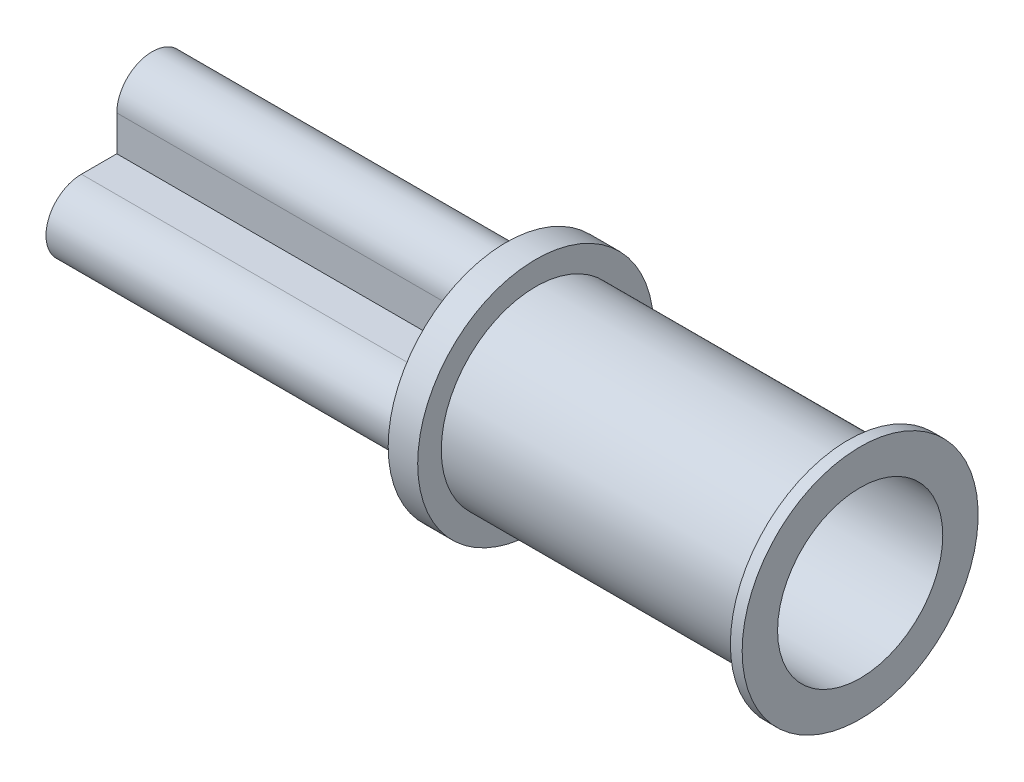
from build123d import *

# Parameters (mm, degrees)
BOSS_EXTRUDE1_DEPTH = 7.62


with BuildPart() as part:
    # Sketch1 → Revolve1 (revolve)
    with BuildSketch(Plane.XY):
        Polygon((0, 1.778), (0, 2.54), (0.635, 2.54), (0.635, 2.032), (7.366, 2.032), (7.366, 2.54), (7.62, 2.54), (7.62, 1.778), (0.635, 1.778), (0.635, 0), (0, 0), align=None)
    revolve(axis=Axis((0, 0, 0), (1, 0, 0)))

    # Sketch3 → Boss-Extrude1 (add)
    with BuildSketch(Plane(origin=(0, 0, 0), x_dir=(0, 0, -1), z_dir=(1, 0, 0))):
        with BuildLine():
            Line((-1.524, 0.762), (-0.762, 0.762))
            Line((-0.762, 0.762), (-0.762, 1.524))
            ThreePointArc((-0.762, 1.524), (0, 2.286), (0.762, 1.524))
            Line((0.762, 1.524), (0.762, 0.762))
            Line((0.762, 0.762), (1.524, 0.762))
            ThreePointArc((1.524, 0.762), (2.286, 0), (1.524, -0.762))
            Line((1.524, -0.762), (0.762, -0.762))
            Line((0.762, -0.762), (0.762, -1.524))
            ThreePointArc((0.762, -1.524), (0, -2.286), (-0.762, -1.524))
            Line((-0.762, -1.524), (-0.762, -0.762))
            Line((-0.762, -0.762), (-1.524, -0.762))
            ThreePointArc((-1.524, -0.762), (-2.286, 0), (-1.524, 0.762))
        make_face()
    extrude(amount=-BOSS_EXTRUDE1_DEPTH)


solid = part.part
